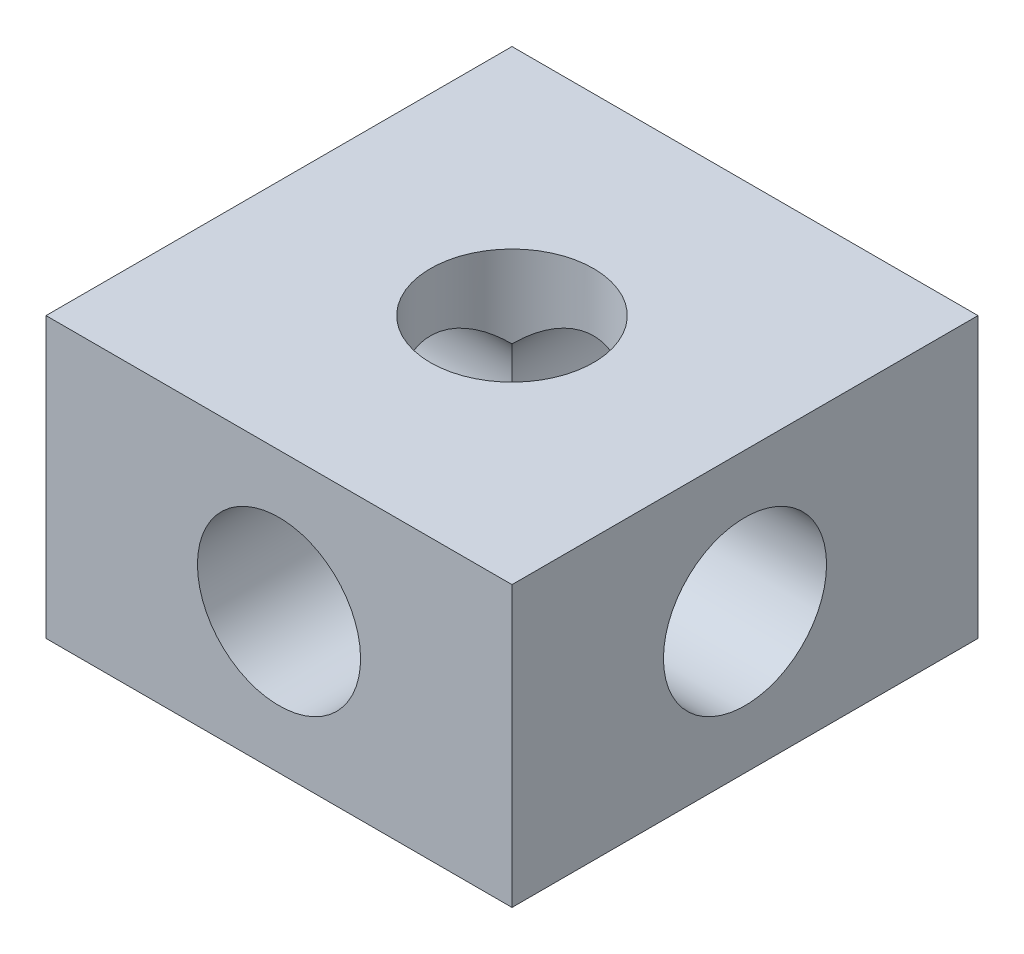
from build123d import *

# Parameters (mm, degrees)
SKETCH_1_W          = 10
SKETCH_1_H          = 10
SKETCH_1_R          = 1.75
EXTRUDE_1_DEPTH     = 3
SKETCH_3_R          = 1.75
CUT_EXTRUDE_1_DEPTH = 8.5
SKETCH_4_R          = 1.75
CUT_EXTRUDE_2_DEPTH = 8.5


with BuildPart() as part:
    # 草图1 → 凸台-拉伸1 (new body, symmetric)
    with BuildSketch(Plane(origin=(0, 0, 0), x_dir=(1, 0, 0), z_dir=(0, 1, 0))):
        Rectangle(SKETCH_1_W, SKETCH_1_H)
        Circle(SKETCH_1_R, mode=Mode.SUBTRACT)
    extrude(amount=EXTRUDE_1_DEPTH, both=True)

    # 草图3 → 切除-拉伸1 (cut, symmetric)
    with BuildSketch(Plane.XY):
        Circle(SKETCH_3_R)
    extrude(amount=CUT_EXTRUDE_1_DEPTH, both=True, mode=Mode.SUBTRACT)

    # 草图4 → 切除-拉伸2 (cut, symmetric)
    with BuildSketch(Plane(origin=(0, 0, 0), x_dir=(0, 0, -1), z_dir=(1, 0, 0))):
        Circle(SKETCH_4_R)
    extrude(amount=CUT_EXTRUDE_2_DEPTH, both=True, mode=Mode.SUBTRACT)


solid = part.part
